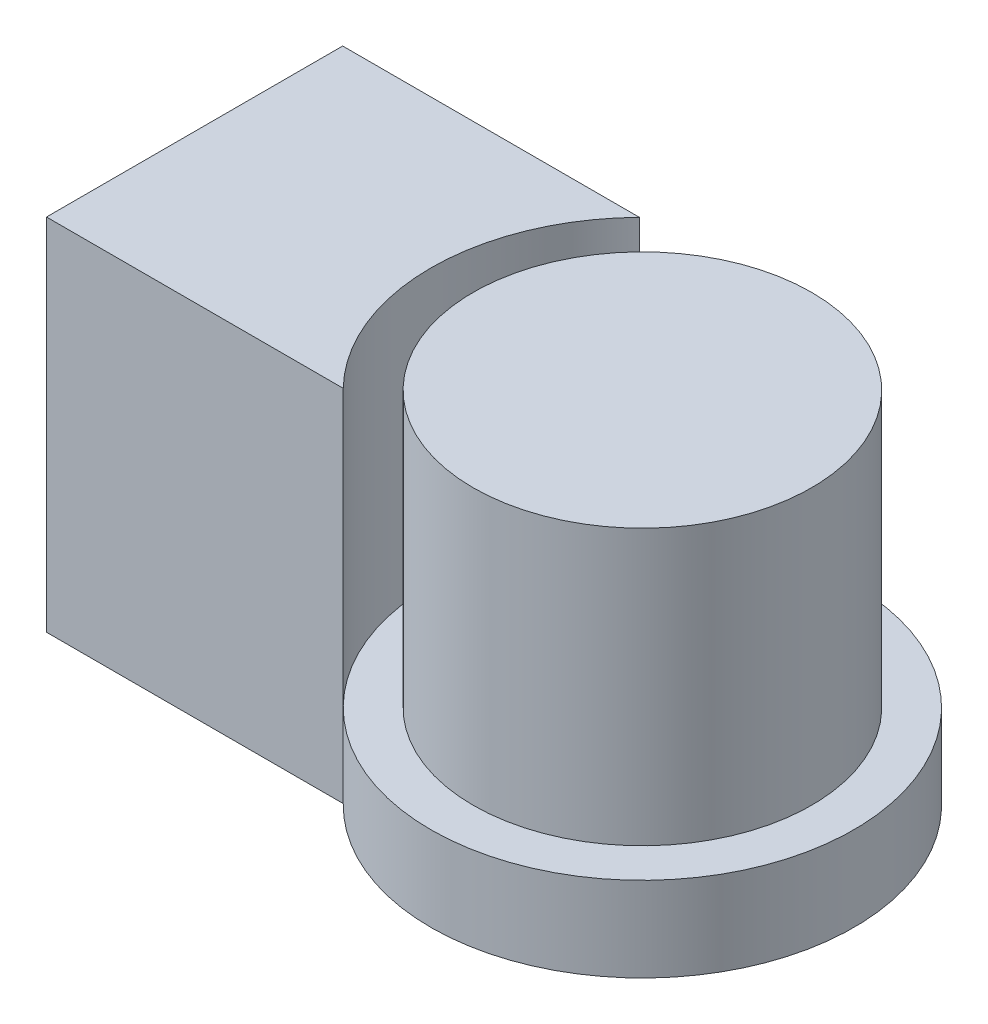
from build123d import *

# Parameters (mm, degrees)
SKETCH1_R      = 50
EXTRUDE1_DEPTH = 20
SKETCH2_R      = 40
EXTRUDE2_DEPTH = 65
EXTRUDE3_DEPTH = 85


with BuildPart() as part:
    # Sketch1 → Extrude1 (new body)
    with BuildSketch(Plane(origin=(0, 0, 0), x_dir=(1, 0, 0), z_dir=(0, 1, 0))):
        with Locations(Location((0, 0, 0), (0, 0, 270))):  # turned: the seam where the file's is
            Circle(SKETCH1_R)
    extrude(amount=EXTRUDE1_DEPTH)

    # Sketch3 → Extrude3 (add)
    with BuildSketch(Plane(origin=(0, 0, 0), x_dir=(1, 0, 0), z_dir=(0, 1, 0))):
        with BuildLine():
            Line((-105.838179272, 35), (-105.838179272, -35))
            Line((-105.838179272, -35), (-35.707142143, -35))
            ThreePointArc((-35.707142143, -35), (-50, 0), (-35.707142143, 35))
            Line((-35.707142143, 35), (-105.838179272, 35))
        make_face()
    extrude(amount=EXTRUDE3_DEPTH)


with BuildPart() as body_2:
    # Sketch2 → Extrude2 (new body)
    with BuildSketch(Plane(origin=(0, 20, 0), x_dir=(-1, 0, 0), z_dir=(0, 1, 0))):
        with Locations(Location((0, 0, 0), (0, 0, 90))):  # turned: the seam where the file's is
            Circle(SKETCH2_R)
    extrude(amount=EXTRUDE2_DEPTH)


solid = Compound([part.part, body_2.part])
